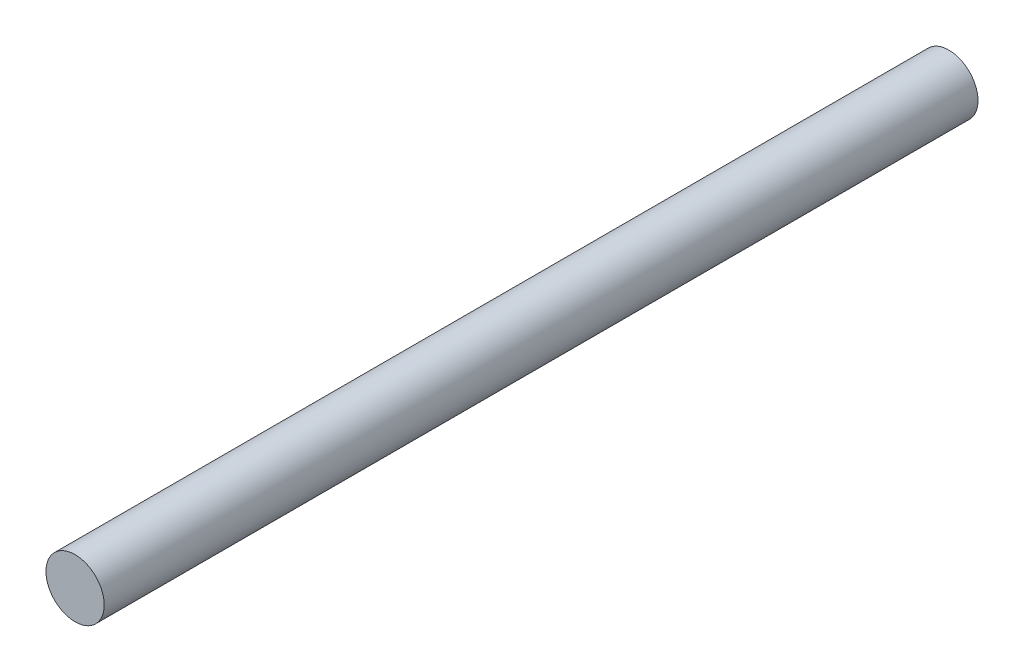
from build123d import *

# Parameters (mm, degrees)
SKETCH2_R           = 6
BOSS_EXTRUDE1_DEPTH = 90


with BuildPart() as part:
    # Sketch2 → Boss-Extrude1 (new body, symmetric)
    with BuildSketch(Plane.XY):
        Circle(SKETCH2_R)
    extrude(amount=BOSS_EXTRUDE1_DEPTH, both=True)


solid = part.part
